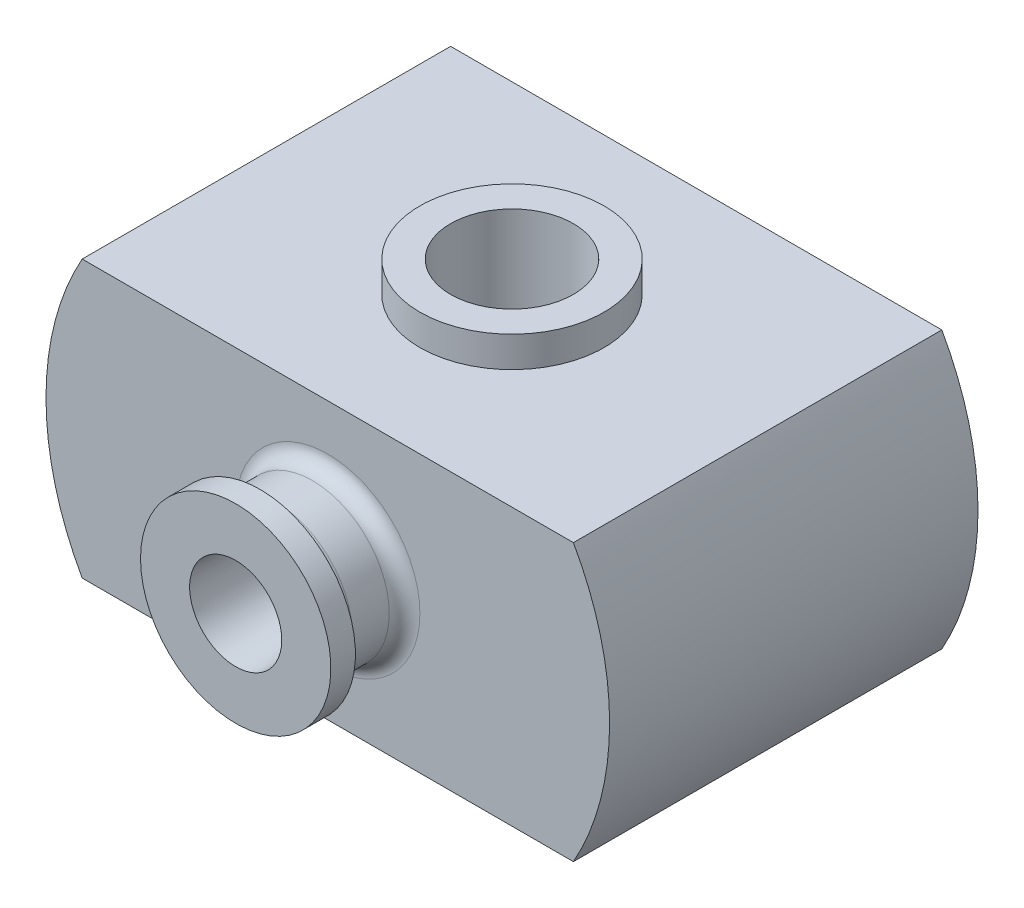
from build123d import *

# Parameters (mm, degrees)
EXTRUDE_1_DEPTH     = 120
CUT_EXTRUDE_1_DEPTH = 114
SKETCH_5_R          = 20
CUT_EXTRUDE_3_DEPTH = 91
EXTRUDE_START       = 25
SKETCH_6_R          = 30
SKETCH_6_R_2        = 20
EXTRUDE_2_DEPTH     = 30
FILLET_2_R          = 5
FILLET_3_R          = 5


with BuildPart() as part:
    # 草图1 → 凸台-拉伸1 (new body)
    with BuildSketch(Plane.XY):
        with BuildLine():
            Line((-80, 45), (80, 45))
            ThreePointArc((80, 45), (91.787798753, 0), (80, -45))
            Line((80, -45), (-80, -45))
            ThreePointArc((-80, -45), (-91.787798753, 0), (-80, 45))
        make_face()
    extrude(amount=EXTRUDE_1_DEPTH)

    # 草图3 → 切除-拉伸1 (cut)
    with BuildSketch(Plane(origin=(0, 0, 0), x_dir=(-1, 0, 0), z_dir=(0, 0, -1))):
        with BuildLine():
            Line((-60, 30), (60, 30))
            ThreePointArc((60, 30), (67.082039325, 0), (60, -30))
            Line((60, -30), (-60, -30))
            ThreePointArc((-60, -30), (-67.082039325, 0), (-60, 30))
        make_face()
    extrude(amount=-CUT_EXTRUDE_1_DEPTH, mode=Mode.SUBTRACT)

    # 草图5 → 切除-拉伸3 (cut, through all)
    with BuildSketch(Plane.XZ.offset(45)):
        with Locations((0, 60)):
            Circle(SKETCH_5_R)
    extrude(amount=-CUT_EXTRUDE_3_DEPTH, mode=Mode.SUBTRACT)

    # 草图6 → 凸台-拉伸2 (add)
    with BuildSketch(Plane(origin=(0, 0, 0), x_dir=(1, 0, 0), z_dir=(0, 1, 0)).offset(EXTRUDE_START)):
        with Locations((0, -60)):
            Circle(SKETCH_6_R)
        with Locations((0, -60)):
            Circle(SKETCH_6_R_2, mode=Mode.SUBTRACT)
    extrude_2 = extrude(amount=EXTRUDE_2_DEPTH)

    # 镜向1: 凸台-拉伸2 across plane
    add(extrude_2.mirror(Plane.ZX))

    # 草图9 → 旋转1 (revolve)
    with BuildSketch(Plane(origin=(0, 0, 0), x_dir=(1, 0, 0), z_dir=(0, 1, 0))):
        Polygon((0, -120), (-25, -120), (-25, -142), (-31, -142), (-31, -150), (0, -150), align=None)
    revolve(axis=Axis((0, 0, -35.705886154), (0, 0, 1)))

    # 圆角2
    fillet_2_edges = [part.edges().sort_by_distance(p)[0] for p in [
        (25, 0, 120),
    ]]
    fillet(fillet_2_edges, radius=FILLET_2_R)

    # 圆角3
    fillet_3_edges = [part.edges().sort_by_distance(p)[0] for p in [
        (25, 0, 142),
    ]]
    fillet(fillet_3_edges, radius=FILLET_3_R)

    # 草图10 → 切除-旋转1 (revolve, cut)
    with BuildSketch(Plane(origin=(0, 0, 0), x_dir=(1, 0, 0), z_dir=(0, 1, 0))):
        Polygon((0, -150), (-15, -150), (-12.5, -105), (0, -105), align=None)
    revolve(axis=Axis((0, 0, 161.939554525), (0, 0, -1)), mode=Mode.SUBTRACT)


solid = part.part
